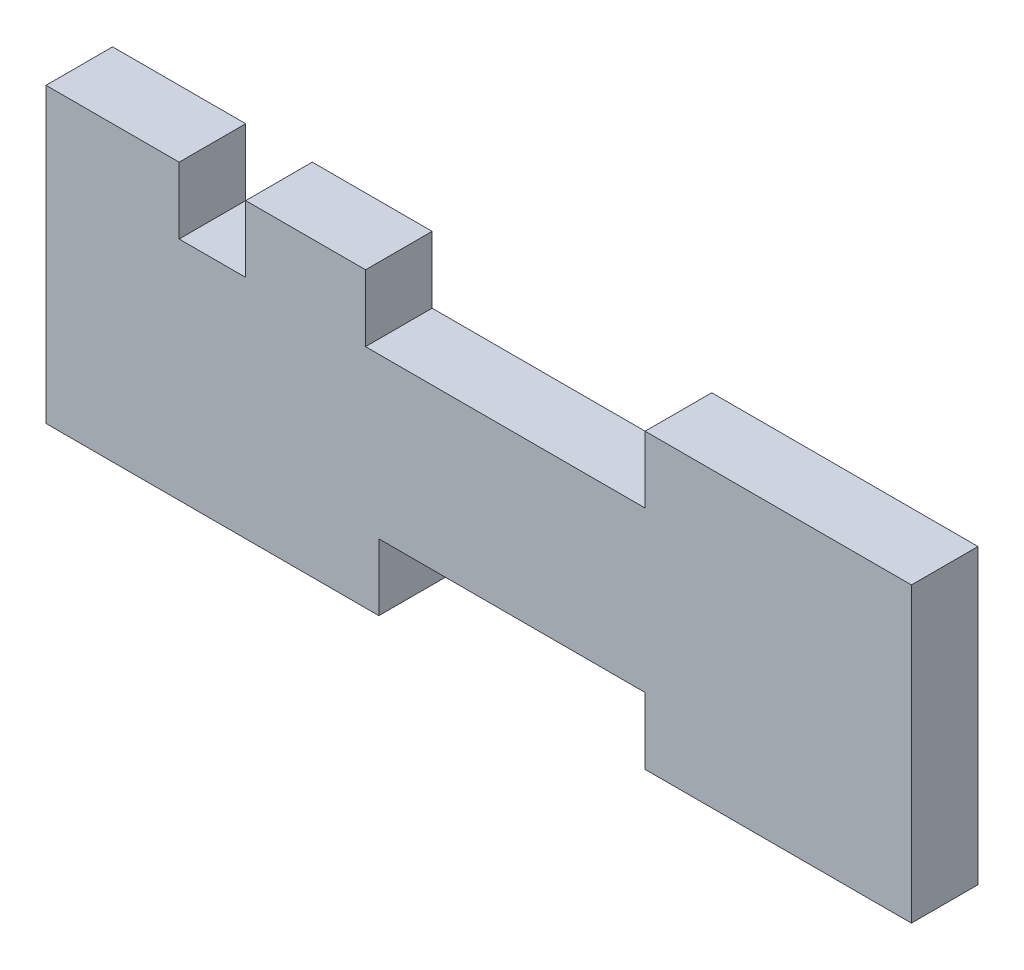
from build123d import *

# Parameters (mm, degrees)
SKETCH1_W           = 10
SKETCH1_H           = 5
SKETCH1_W_2         = 25
SKETCH1_W_3         = 20
BOSS_EXTRUDE1_DEPTH = 5
SKETCH2_W           = 5
SKETCH2_H           = 5
CUT_EXTRUDE1_DEPTH  = 1


with BuildPart() as part:
    # Sketch1 → Boss-Extrude1 (new body)
    with BuildSketch(Plane.XY):
        Polygon((-20, 0), (0, 0), (0, 12), (-20, 12), (-40, 12), (-50, 12), (-55, 12), (-65, 12), (-65, 0), (-40, 0), align=None)
        with Locations((-60, 14.5)):
            Rectangle(SKETCH1_W, SKETCH1_H)
        with Locations((-45, 14.5)):
            Rectangle(SKETCH1_W, SKETCH1_H)
        with Locations((-52.5, -2.5)):
            Rectangle(SKETCH1_W_2, SKETCH1_H)
        with Locations((-10, -2.5)):
            Rectangle(SKETCH1_W_3, SKETCH1_H)
        with Locations((-10, 14.5)):
            Rectangle(SKETCH1_W_3, SKETCH1_H)
    extrude(amount=BOSS_EXTRUDE1_DEPTH)

    # Sketch2 → Cut-Extrude1 (cut)
    with BuildSketch(Plane(origin=(-40, 0, 0), x_dir=(0, 0, -1), z_dir=(1, 0, 0))):
        with Locations((-2.5, 14.5)):
            Rectangle(SKETCH2_W, SKETCH2_H)
    extrude(amount=-CUT_EXTRUDE1_DEPTH, mode=Mode.SUBTRACT)


solid = part.part
